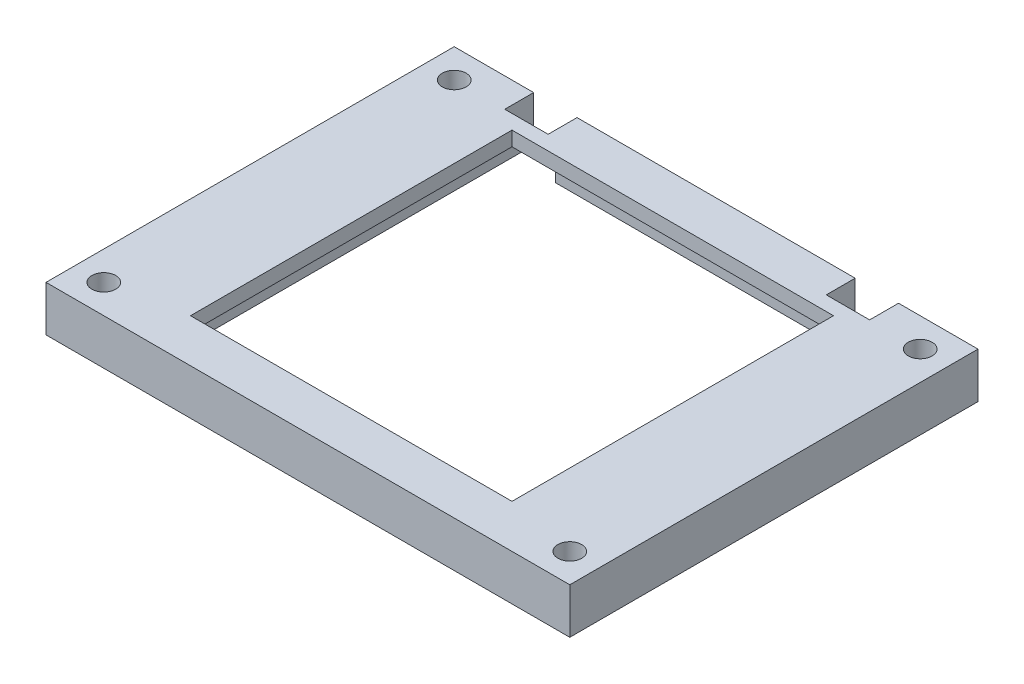
from build123d import *

# Parameters (mm, degrees)
SKETCH1_W           = 56.5
SKETCH1_H           = 56.5
SKETCH1_W_2         = 50.5
SKETCH1_H_2         = 50.5
SKETCH1_R           = 1.65
BOSS_EXTRUDE1_DEPTH = 8.6
SKETCH2_W           = 50.5
SKETCH2_H           = 50.5
SKETCH2_W_2         = 44.5
SKETCH2_H_2         = 44.5
BOSS_EXTRUDE2_DEPTH = 2
BOSS_EXTRUDE3_START = 6.6
SKETCH4_W           = 50.5
SKETCH4_H           = 50.5
SKETCH4_W_2         = 44.5
SKETCH4_H_2         = 44.5
BOSS_EXTRUDE3_DEPTH = 2
CUT_EXTRUDE1_START  = 2
SKETCH5_W           = 6
SKETCH5_H           = 17.961455198
CUT_EXTRUDE1_DEPTH  = 4.6
SKETCH6_W           = 87.3205389
SKETCH6_H           = 82.15723747
CUT_EXTRUDE2_DEPTH  = 2.3
CUT_EXTRUDE4_DEPTH  = 10
SKETCH8_W           = 8
SKETCH8_H           = 40.5
BOSS_EXTRUDE4_DEPTH = 6.3
SKETCH9_W           = 6
SKETCH9_H           = 6.3
CUT_EXTRUDE5_DEPTH  = 4


with BuildPart() as part:
    # Sketch1 → Boss-Extrude1 (new body)
    with BuildSketch(Plane(origin=(0, 0, 0), x_dir=(1, 0, 0), z_dir=(0, 1, 0))):
        Rectangle(SKETCH1_W, SKETCH1_H)
        Rectangle(SKETCH1_W_2, SKETCH1_H_2, mode=Mode.SUBTRACT)
        Polygon((-28.25, -28.25), (-28.25, -12.25), (-36.25, -20.25), (-36.25, -30.25), (-32.25, -34.25), (-24.25, -34.25), (-18.25, -28.25), align=None)
        with Locations((-32.25, -24.25)):
            Circle(SKETCH1_R, mode=Mode.SUBTRACT)
        Polygon((28.25, -28.25), (18.25, -28.25), (24.25, -34.25), (32.25, -34.25), (36.25, -30.25), (36.25, -20.25), (28.25, -12.25), align=None)
        with Locations((32.25, -24.25)):
            Circle(SKETCH1_R, mode=Mode.SUBTRACT)
        Polygon((24.25, 34.25), (18.25, 28.25), (28.25, 28.25), (28.25, 12.25), (36.25, 20.25), (36.25, 30.25), (32.25, 34.25), align=None)
        with Locations((32.25, 24.25)):
            Circle(SKETCH1_R, mode=Mode.SUBTRACT)
        Polygon((-36.25, 20.25), (-28.25, 12.25), (-28.25, 28.25), (-18.25, 28.25), (-24.25, 34.25), (-32.25, 34.25), (-36.25, 30.25), align=None)
        with Locations((-32.25, 24.25)):
            Circle(SKETCH1_R, mode=Mode.SUBTRACT)
    extrude(amount=BOSS_EXTRUDE1_DEPTH)

    # Sketch2 → Boss-Extrude2 (add)
    with BuildSketch(Plane(origin=(0, 0, 0), x_dir=(1, 0, 0), z_dir=(0, 1, 0))):
        Rectangle(SKETCH2_W, SKETCH2_H)
        Rectangle(SKETCH2_W_2, SKETCH2_H_2, mode=Mode.SUBTRACT)
    extrude(amount=BOSS_EXTRUDE2_DEPTH)

    # Sketch4 → Boss-Extrude3 (add)
    with BuildSketch(Plane(origin=(0, 0, 0), x_dir=(1, 0, 0), z_dir=(0, 1, 0)).offset(BOSS_EXTRUDE3_START)):
        Rectangle(SKETCH4_W, SKETCH4_H)
        Rectangle(SKETCH4_W_2, SKETCH4_H_2, mode=Mode.SUBTRACT)
    extrude(amount=BOSS_EXTRUDE3_DEPTH)

    # Sketch5 → Cut-Extrude1 (cut)
    with BuildSketch(Plane(origin=(0, 0, 0), x_dir=(1, 0, 0), z_dir=(0, 1, 0)).offset(CUT_EXTRUDE1_START)):
        with Locations((-22.25, 28.869783692)):
            Rectangle(SKETCH5_W, SKETCH5_H)
        with Locations((22.25, 28.869783692)):
            Rectangle(SKETCH5_W, SKETCH5_H)
    extrude(amount=CUT_EXTRUDE1_DEPTH, mode=Mode.SUBTRACT)

    # Sketch6 → Cut-Extrude2 (cut)
    with BuildSketch(Plane.XZ):
        with Locations((1.898272585, -1.518618068)):
            Rectangle(SKETCH6_W, SKETCH6_H)
    extrude(amount=-CUT_EXTRUDE2_DEPTH, mode=Mode.SUBTRACT)

    # Sketch7 → Cut-Extrude4 (cut)
    with BuildSketch(Plane(origin=(0, 8.6, 0), x_dir=(1, 0, 0), z_dir=(0, 1, 0))):
        Polygon((-36.25, -30.25), (-36.25, -28.25), (-40.881768663, -28.25), (-40.881768663, -34.995320637), (0, -34.995320637), (0, -28.25), (-18.25, -28.25), (-24.25, -34.25), (-32.25, -34.25), align=None)
        Polygon((18.25, -28.25), (0, -28.25), (0, -34.995320637), (39.184342226, -34.995320637), (39.184342226, -28.25), (36.25, -28.25), (36.25, -30.25), (32.25, -34.25), (24.25, -34.25), align=None)
        Polygon((36.25, 20.25), (36.25, -20.25), (28.25, -12.25), (28.25, 12.25), align=None)
        Polygon((-36.25, 20.25), (-36.25, -20.25), (-28.25, -12.25), (-28.25, 12.25), align=None)
        Polygon((-36.25, 30.25), (-36.25, 28.25), (-18.25, 28.25), (-24.25, 34.25), (-32.25, 34.25), align=None)
        Polygon((-38.207606214, 28.25), (-36.25, 28.25), (-36.25, 30.25), (-32.25, 34.25), (-24.25, 34.25), (-18.25, 28.25), (0, 28.25), (0, 36.724555445), (-38.207606214, 36.724555445), align=None)
        Polygon((28.25, 12.25), (36.25, 20.25), (28.25, 20.25), align=None)
        Polygon((28.25, -20.25), (36.25, -20.25), (28.25, -12.25), align=None)
        Polygon((-18.25, -28.25), (-36.25, -28.25), (-36.25, -30.25), (-32.25, -34.25), (-24.25, -34.25), align=None)
        Polygon((-28.25, -12.25), (-36.25, -20.25), (-28.25, -20.25), align=None)
        Polygon((-28.25, 20.25), (-36.25, 20.25), (-28.25, 12.25), align=None)
        Polygon((24.25, 34.25), (18.25, 28.25), (36.25, 28.25), (36.25, 30.25), (32.25, 34.25), align=None)
        Polygon((0, 36.724555445), (0, 28.25), (18.25, 28.25), (24.25, 34.25), (32.25, 34.25), (36.25, 30.25), (36.25, 28.25), (40.981198071, 28.25), (40.981198071, 36.724555445), align=None)
        Polygon((36.25, -28.25), (18.25, -28.25), (24.25, -34.25), (32.25, -34.25), (36.25, -30.25), align=None)
    extrude(amount=-CUT_EXTRUDE4_DEPTH, mode=Mode.SUBTRACT)

    # Sketch8 → Boss-Extrude4 (add)
    with BuildSketch(Plane(origin=(0, 8.6, 0), x_dir=(1, 0, 0), z_dir=(0, 1, 0))):
        with Locations((-32.25, 0)):
            Rectangle(SKETCH8_W, SKETCH8_H)
        with Locations((32.25, 0)):
            Rectangle(SKETCH8_W, SKETCH8_H)
    extrude(amount=-BOSS_EXTRUDE4_DEPTH)

    # Sketch9 → Cut-Extrude5 (cut)
    with BuildSketch(Plane(origin=(0, 0, -28.25), x_dir=(-1, 0, 0), z_dir=(0, 0, -1))):
        with Locations((-22.25, 5.45)):
            Rectangle(SKETCH9_W, SKETCH9_H)
        with Locations((22.25, 5.45)):
            Rectangle(SKETCH9_W, SKETCH9_H)
    extrude(amount=-CUT_EXTRUDE5_DEPTH, mode=Mode.SUBTRACT)


solid = part.part
